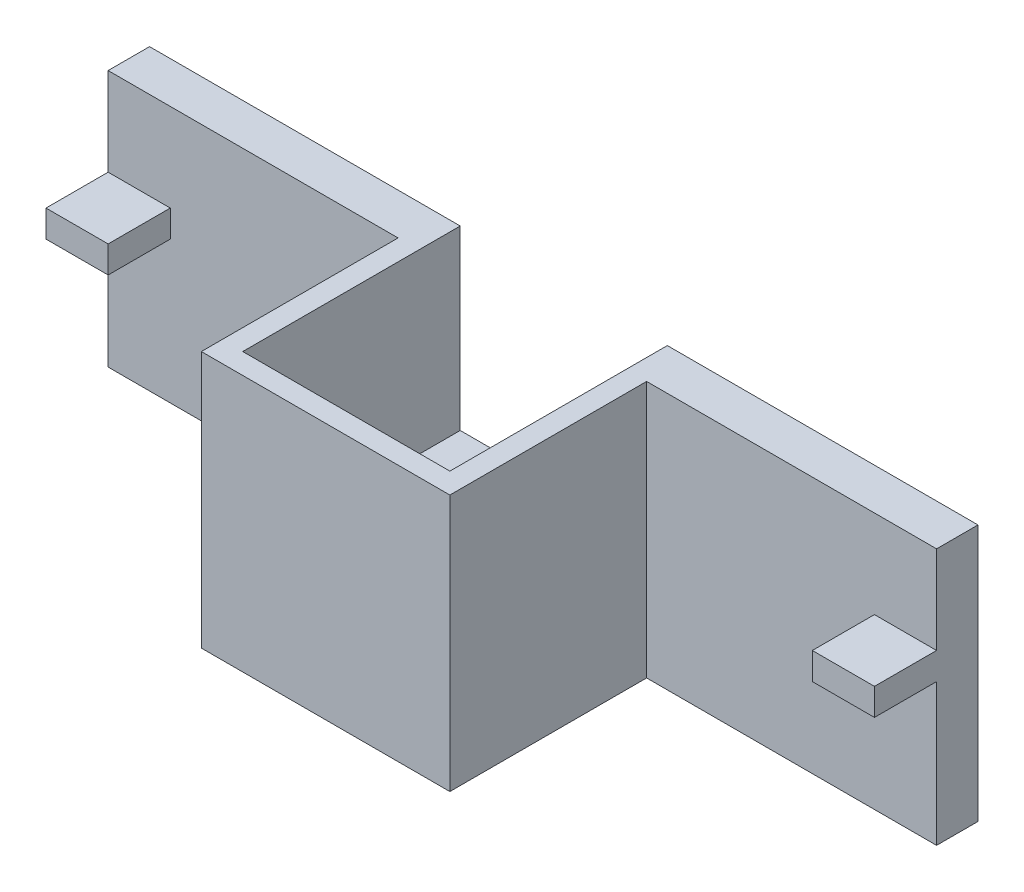
from build123d import *

# Parameters (mm, degrees)
SKETCH1_W           = 80
SKETCH1_H           = 4
BOSS_EXTRUDE1_DEPTH = 24.8
SKETCH2_W           = 6
SKETCH2_H           = 2.6
BOSS_EXTRUDE2_DEPTH = 6
SKETCH3_W           = 20
SKETCH3_H           = 24.8
CUT_EXTRUDE1_DEPTH  = 10
EXTRUDE_THIN1_DEPTH = 24.8
SKETCH5_W           = 20
SKETCH5_H           = 21
BOSS_EXTRUDE3_DEPTH = 7.7


with BuildPart() as part:
    # Sketch1 → Boss-Extrude1 (new body)
    with BuildSketch(Plane(origin=(0, 0, 0), x_dir=(1, 0, 0), z_dir=(0, 1, 0))):
        with Locations((40, 2)):
            Rectangle(SKETCH1_W, SKETCH1_H)
    extrude(amount=BOSS_EXTRUDE1_DEPTH)

    # Sketch2 → Boss-Extrude2 (add)
    with BuildSketch(Plane.XY):
        with Locations((3, 15)):
            Rectangle(SKETCH2_W, SKETCH2_H)
        with Locations((77, 15)):
            Rectangle(SKETCH2_W, SKETCH2_H)
    extrude(amount=BOSS_EXTRUDE2_DEPTH)

    # Sketch3 → Cut-Extrude1 (cut)
    with BuildSketch(Plane.XY):
        with Locations((40, 12.4)):
            Rectangle(SKETCH3_W, SKETCH3_H)
    extrude(amount=-CUT_EXTRUDE1_DEPTH, mode=Mode.SUBTRACT)

    # Sketch4 → Extrude-Thin1 (add)
    with BuildSketch(Plane.XZ):
        Polygon((30, 0), (30, 17), (50, 17), (50, 0), (52, 0), (52, 19), (28, 19), (28, 0), align=None)
    extrude(amount=-EXTRUDE_THIN1_DEPTH)

    # Sketch5 → Boss-Extrude3 (add)
    with BuildSketch(Plane.XZ):
        with Locations((40, 6.5)):
            Rectangle(SKETCH5_W, SKETCH5_H)
    extrude(amount=-BOSS_EXTRUDE3_DEPTH)


solid = part.part
